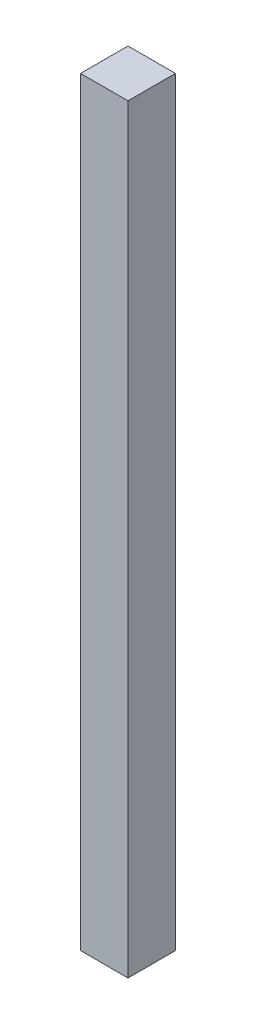
from build123d import *

# Parameters (mm, degrees)
SKETCH1_W           = 20
SKETCH1_H           = 20
BOSS_EXTRUDE1_DEPTH = 320


with BuildPart() as part:
    # Sketch1 → Boss-Extrude1 (new body)
    with BuildSketch(Plane(origin=(0, 0, 0), x_dir=(1, 0, 0), z_dir=(0, 1, 0))):
        Rectangle(SKETCH1_W, SKETCH1_H)
    extrude(amount=BOSS_EXTRUDE1_DEPTH)


solid = part.part
